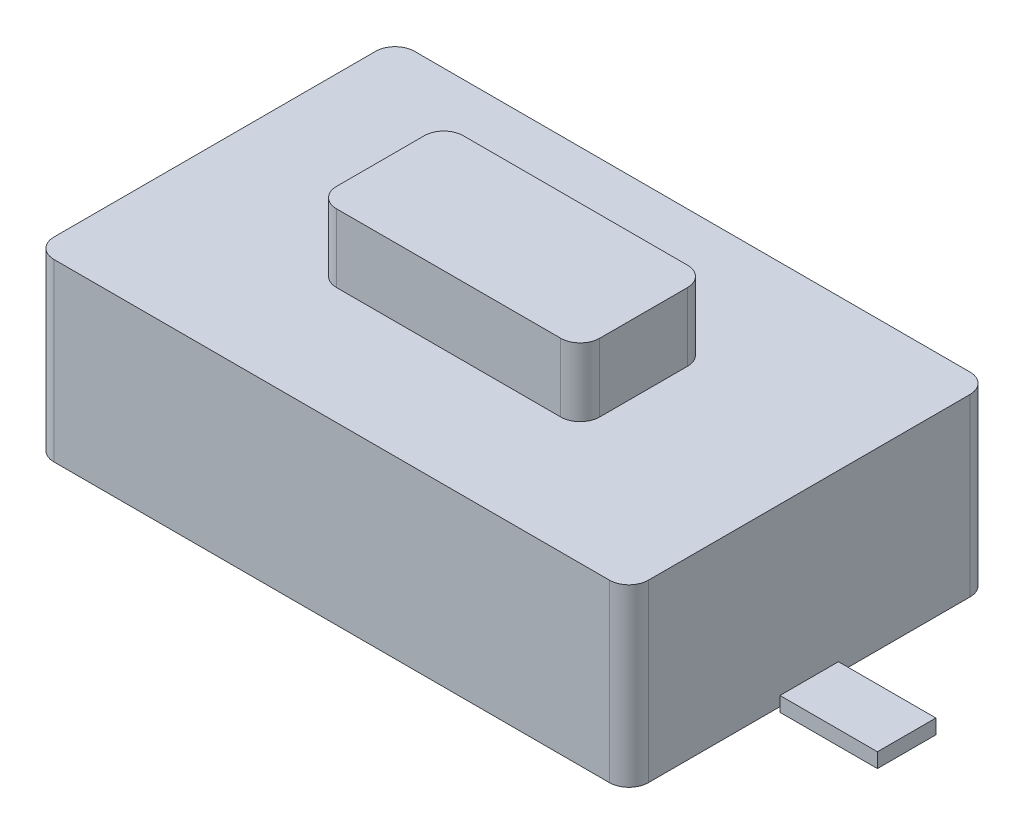
from build123d import *

# Parameters (mm, degrees)
SKETCH_1_W      = 6.1
SKETCH_1_H      = 3.7
EXTRUDE_1_DEPTH = 1.8
SKETCH_3_W      = 2.7
SKETCH_3_H      = 1.3
EXTRUDE_2_DEPTH = 0.7
EXTRUDE_START   = -0.1
SKETCH_4_W      = 1
SKETCH_4_H      = 0.6
EXTRUDE_3_DEPTH = 0.15
FILLET_1_R      = 0.2
FILLET_2_R      = 0.2


with BuildPart() as part:
    # Эскиз1 → Бобышка-Вытянуть1 (new body)
    with BuildSketch(Plane(origin=(0, 0, 0), x_dir=(1, 0, 0), z_dir=(0, 1, 0))):
        Rectangle(SKETCH_1_W, SKETCH_1_H)
    extrude(amount=EXTRUDE_1_DEPTH)

    # Эскиз3 → Бобышка-Вытянуть2 (add)
    with BuildSketch(Plane(origin=(0, 1.8, 0), x_dir=(1, 0, 0), z_dir=(0, 1, 0))):
        Rectangle(SKETCH_3_W, SKETCH_3_H)
    extrude(amount=EXTRUDE_2_DEPTH)

    # Эскиз4 → Бобышка-Вытянуть3 (add)
    with BuildSketch(Plane.XZ.offset(EXTRUDE_START)):
        with Locations((-3.55, 0)):
            Rectangle(SKETCH_4_W, SKETCH_4_H)
    extrude_3 = extrude(amount=EXTRUDE_3_DEPTH)

    # Зеркальное отражение1: Бобышка-Вытянуть3 across plane
    add(extrude_3.mirror(Plane(origin=(0, 0, 0), x_dir=(0, 0, 1), z_dir=(1, 0, 0))))

    # Скругление1
    fillet_1_edges = [part.edges().sort_by_distance(p)[0] for p in [
        (1.35, 2.15, 0.65),
        (1.35, 2.15, -0.65),
        (-1.35, 2.15, -0.65),
        (-1.35, 2.15, 0.65),
    ]]
    fillet(fillet_1_edges, radius=FILLET_1_R)

    # Скругление2
    fillet_2_edges = [part.edges().sort_by_distance(p)[0] for p in [
        (3.05, 0.9, 1.85),
        (-3.05, 0.9, 1.85),
        (-3.05, 0.9, -1.85),
        (3.05, 0.9, -1.85),
    ]]
    fillet(fillet_2_edges, radius=FILLET_2_R)


solid = part.part
